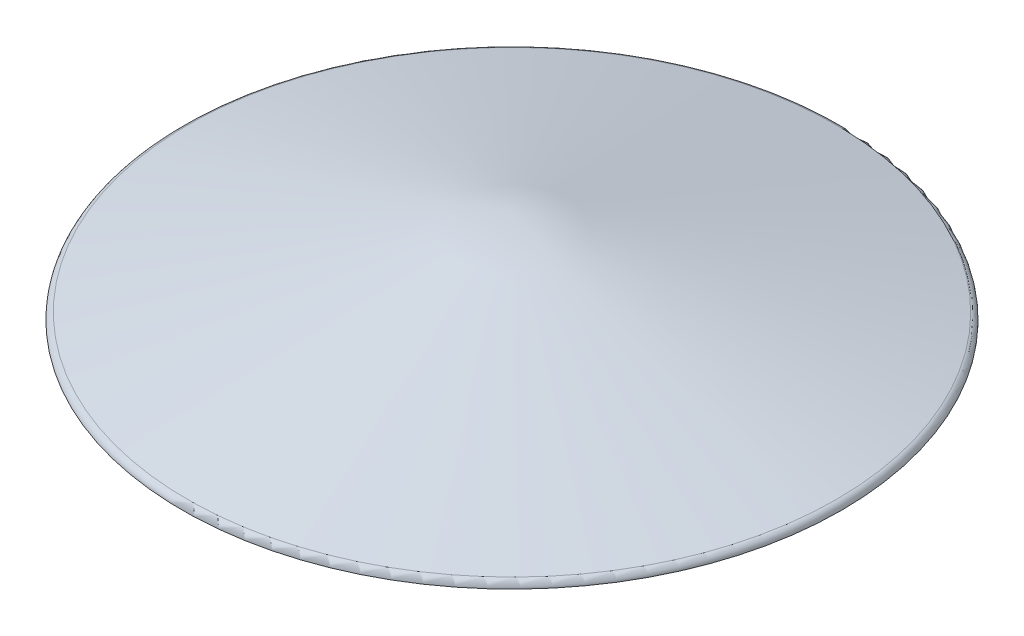
from build123d import *


with BuildPart() as part:
    # Esquisse1 → R_volution1 (revolve)
    with BuildSketch(Plane.XY, mode=Mode.PRIVATE) as r_volution1_sk:
        with BuildLine():
            Line((-1477.764571353, 28.977774789), (0, 424.943598286))
            Line((0, 424.943598286), (0, 427.014150647))
            Line((0, 427.014150647), (-1478.282209443, 30.909626441))
            ThreePointArc((-1478.282209443, 30.909626441), (-1495.387306889, 19.480365728), (-1502, 0))
            Line((-1502, 0), (-1500, 0))
            ThreePointArc((-1500, 0), (-1493.800600209, 18.26284287), (-1477.764571353, 28.977774789))
        make_face()
    revolve(r_volution1_sk.sketch.rotate(Axis((0, 424.943598286, 0), (0, 1, 0)), 180), axis=Axis((0, 424.943598286, 0), (0, 1, 0)))  # turned: the seam where the file's is


solid = part.part
